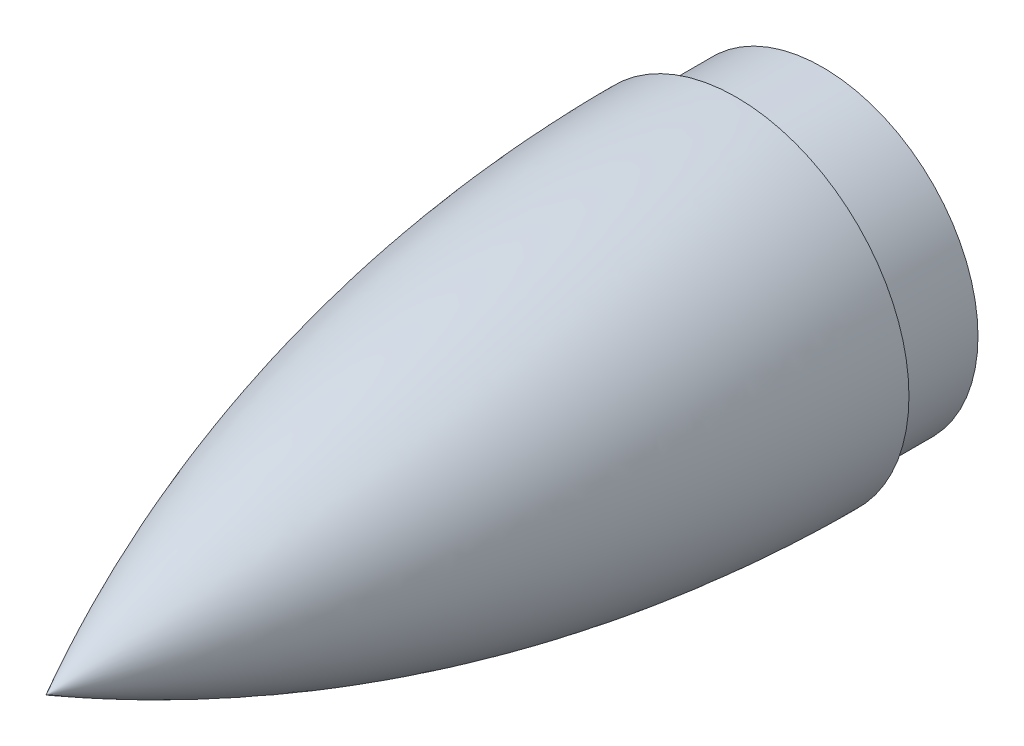
from build123d import *


with BuildPart() as part:
    # Sketch2 → Revolve1 (revolve)
    with BuildSketch(Plane(origin=(0, 0, 0), x_dir=(0, 0, -1), z_dir=(1, 0, 0))):
        with BuildLine():
            Line((80, 20.000000007), (80, 18))
            Line((80, 18), (89.999999999, 18))
            Line((89.999999999, 18), (89.999999999, -1e-09))
            Line((89.999999999, -1e-09), (-1e-09, -1e-09))
            add(Edge.make_bspline(
                [(-1e-09, -1e-09), (9.999999999, 5.333319453), (19.999999999, 9.688103693), (29.999999999, 13.203130539), (39.999999999, 15.951343155), (49.999999999, 17.983274917), (60, 19.327698379), (70, 20.000008008), (80, 20.000000007)],
                knots=[0.075871555, 0.075871555, 0.075871555, 0.075871555, 0.075871555, 0.075871555, 0.075871555, 0.075871555, 0.075871555, 0.915988323, 0.915988323, 0.915988323, 0.915988323, 0.915988323, 0.915988323, 0.915988323, 0.915988323, 0.915988323], degree=8))
        make_face()
    revolve(axis=Axis((0, -1e-09, 1e-09), (0, 0, -1)))


solid = part.part
